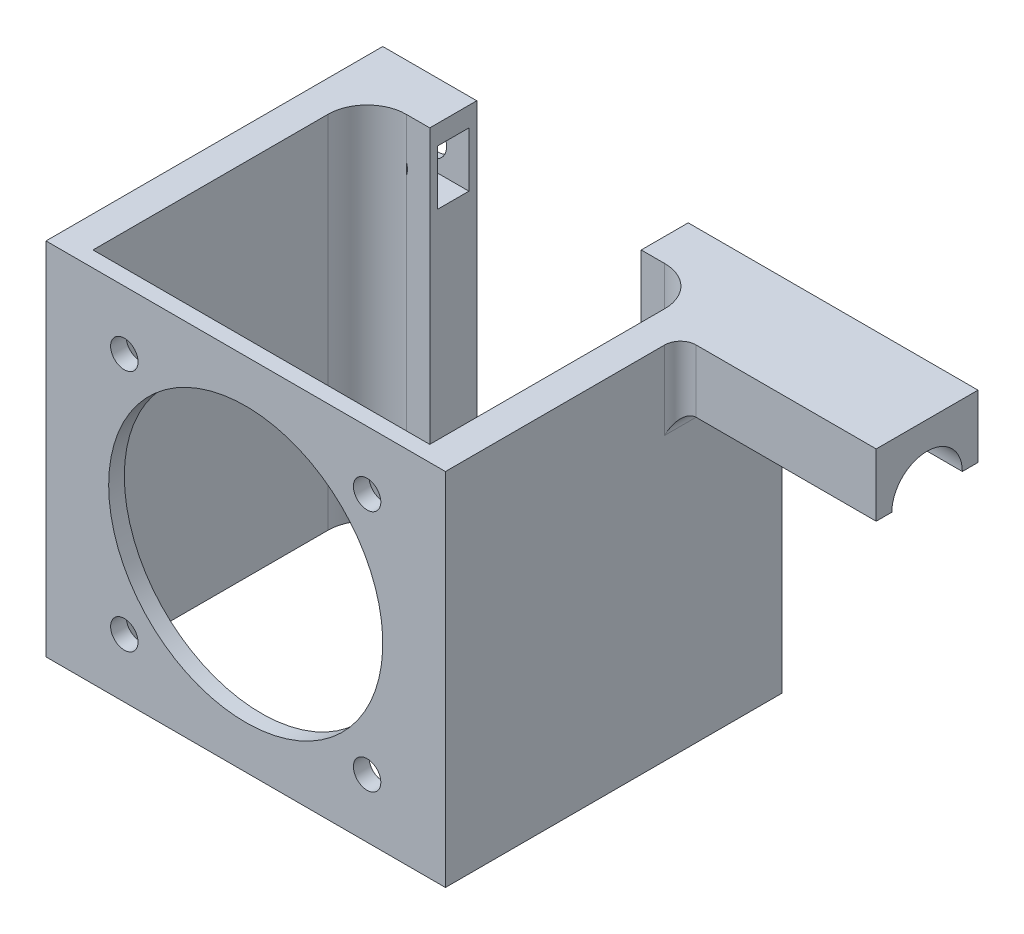
from build123d import *

# Parameters (mm, degrees)
SKETCH1_W           = 51
SKETCH1_H           = 46
BOSS_EXTRUDE1_DEPTH = 2
SKETCH2_W           = 4
SKETCH2_H           = 46
BOSS_EXTRUDE2_DEPTH = 35
SKETCH3_R           = 1.75
CUT_EXTRUDE1_DEPTH  = 30
SKETCH4_W           = 12
SKETCH4_H           = 46
BOSS_EXTRUDE3_DEPTH = 6
FILLET1_R           = 5
SKETCH5_R           = 2.15
CUT_EXTRUDE2_DEPTH  = 6
SKETCH6_W           = 4
SKETCH6_H           = 7
CUT_EXTRUDE3_DEPTH  = 11
SKETCH7_W           = 4
SKETCH7_H           = 7
CUT_EXTRUDE4_DEPTH  = 11
SKETCH8_R           = 17.5
CUT_EXTRUDE5_DEPTH  = 11
SKETCH9_W           = 13
SKETCH9_H           = 8
BOSS_EXTRUDE4_DEPTH = 25
SKETCH10_R          = 4.5
CUT_EXTRUDE6_DEPTH  = 25
FILLET2_R           = 2


with BuildPart() as part:
    # Sketch1 → Boss-Extrude1 (new body)
    with BuildSketch(Plane.XY):
        Rectangle(SKETCH1_W, SKETCH1_H)
    extrude(amount=BOSS_EXTRUDE1_DEPTH)

    # Sketch2 → Boss-Extrude2 (add)
    with BuildSketch(Plane.XY):
        with Locations((23.5, 0)):
            Rectangle(SKETCH2_W, SKETCH2_H)
        with Locations((-23.5, 0)):
            Rectangle(SKETCH2_W, SKETCH2_H)
    extrude(amount=-BOSS_EXTRUDE2_DEPTH)

    # Sketch3 → Cut-Extrude1 (cut)
    with BuildSketch(Plane(origin=(0, 0, 0), x_dir=(-1, 0, 0), z_dir=(0, 0, -1))):
        with Locations((15.5, -15.5)):
            Circle(SKETCH3_R)
        with Locations((-15.5, -15.5)):
            Circle(SKETCH3_R)
        with Locations((-15.5, 15.5)):
            Circle(SKETCH3_R)
        with Locations((15.5, 15.5)):
            Circle(SKETCH3_R)
    extrude(amount=-CUT_EXTRUDE1_DEPTH, mode=Mode.SUBTRACT)

    # Sketch4 → Boss-Extrude3 (add)
    with BuildSketch(Plane(origin=(0, 0, -35), x_dir=(-1, 0, 0), z_dir=(0, 0, -1))):
        with Locations((-19.5, 0)):
            Rectangle(SKETCH4_W, SKETCH4_H)
        with Locations((19.5, 0)):
            Rectangle(SKETCH4_W, SKETCH4_H)
    extrude(amount=BOSS_EXTRUDE3_DEPTH)

    # Fillet1
    fillet1_edges = [part.edges().sort_by_distance(p)[0] for p in [
        (21.5, 0, -35),
        (-21.5, 0, -35),
    ]]
    fillet(fillet1_edges, radius=FILLET1_R)

    # Sketch5 → Cut-Extrude2 (cut)
    with BuildSketch(Plane(origin=(0, 0, -41), x_dir=(-1, 0, 0), z_dir=(0, 0, -1))):
        with Locations((-18.5, -17)):
            Circle(SKETCH5_R)
        with Locations((-18.5, 17)):
            Circle(SKETCH5_R)
        with Locations((18.5, 17)):
            Circle(SKETCH5_R)
        with Locations((18.5, -17)):
            Circle(SKETCH5_R)
    extrude(amount=-CUT_EXTRUDE2_DEPTH, mode=Mode.SUBTRACT)

    # Sketch6 → Cut-Extrude3 (cut)
    with BuildSketch(Plane(origin=(-13.5, 0, 0), x_dir=(0, 0, -1), z_dir=(1, 0, 0))):
        with Locations((38, 17)):
            Rectangle(SKETCH6_W, SKETCH6_H)
        with Locations((38, -17)):
            Rectangle(SKETCH6_W, SKETCH6_H)
    extrude(amount=-CUT_EXTRUDE3_DEPTH, mode=Mode.SUBTRACT)

    # Sketch7 → Cut-Extrude4 (cut)
    with BuildSketch(Plane.ZY.offset(-13.5)):
        with Locations((-38, -17)):
            Rectangle(SKETCH7_W, SKETCH7_H)
        with Locations((-38, 17)):
            Rectangle(SKETCH7_W, SKETCH7_H)
    extrude(amount=-CUT_EXTRUDE4_DEPTH, mode=Mode.SUBTRACT)

    # Sketch8 → Cut-Extrude5 (cut)
    with BuildSketch(Plane(origin=(0, 0, 0), x_dir=(-1, 0, 0), z_dir=(0, 0, -1))):
        Circle(SKETCH8_R)
    extrude(amount=-CUT_EXTRUDE5_DEPTH, mode=Mode.SUBTRACT)

    # Sketch9 → Boss-Extrude4 (add)
    with BuildSketch(Plane.ZY.offset(-25.5)):
        with Locations((-34.5, 19)):
            Rectangle(SKETCH9_W, SKETCH9_H)
    extrude(amount=-BOSS_EXTRUDE4_DEPTH)

    # Sketch10 → Cut-Extrude6 (cut)
    with BuildSketch(Plane(origin=(50.5, 0, 0), x_dir=(0, 0, -1), z_dir=(1, 0, 0))):
        with Locations((34.5, 15)):
            Circle(SKETCH10_R)
    extrude(amount=-CUT_EXTRUDE6_DEPTH, mode=Mode.SUBTRACT)

    # Fillet2
    fillet2_edges = [part.edges().sort_by_distance(p)[0] for p in [
        (25.5, 19, -28),
        (25.5, 15, -29),
        (25.5, 19.5, -34.5),
        (25.5, 15, -40),
    ]]
    fillet(fillet2_edges, radius=FILLET2_R)


solid = part.part
